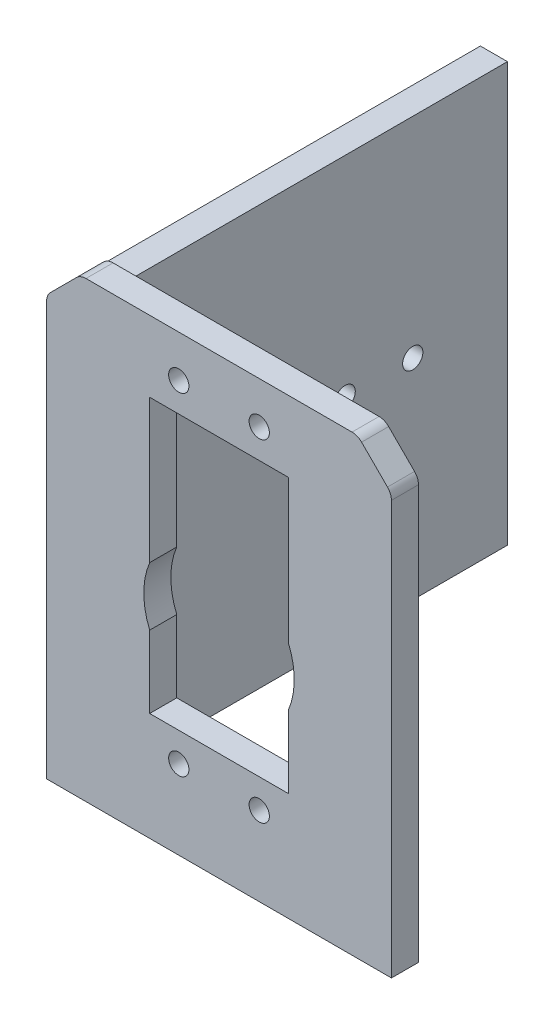
from build123d import *

# Parameters (mm, degrees)
SKETCH1_R           = 1.5
BOSS_EXTRUDE3_DEPTH = 4
SKETCH2_W           = 4
SKETCH2_H           = 61.93693974
BOSS_EXTRUDE4_DEPTH = 60
SKETCH3_R           = 1.5
CUT_EXTRUDE2_DEPTH  = 10


with BuildPart() as part:
    # Sketch1 → Boss-Extrude3 (new body)
    with BuildSketch(Plane.XY):
        with BuildLine():
            Line((0, 61.171572875), (0, 0))
            Line((0, 0), (51, 0))
            Line((51, 0), (51, 61.171572875))
            ThreePointArc((51, 61.171572875), (50.847759065, 61.93693974), (50.414213562, 62.585786438))
            Line((50.414213562, 62.585786438), (46.585786438, 66.414213562))
            ThreePointArc((46.585786438, 66.414213562), (45.93693974, 66.847759065), (45.171572875, 67))
            Line((45.171572875, 67), (5.828427125, 67))
            ThreePointArc((5.828427125, 67), (5.06306026, 66.847759065), (4.414213562, 66.414213562))
            Line((4.414213562, 66.414213562), (0.585786438, 62.585786438))
            ThreePointArc((0.585786438, 62.585786438), (0.152240935, 61.93693974), (0, 61.171572875))
        make_face()
        with Locations((19.55, 11.7)):
            Circle(SKETCH1_R, mode=Mode.SUBTRACT)
        with Locations((31.45, 11.7)):
            Circle(SKETCH1_R, mode=Mode.SUBTRACT)
        with Locations((31.45, 60.8)):
            Circle(SKETCH1_R, mode=Mode.SUBTRACT)
        with Locations((19.55, 60.8)):
            Circle(SKETCH1_R, mode=Mode.SUBTRACT)
        with BuildLine():
            Line((15.25, 56.5), (35.75, 56.5))
            Line((35.75, 56.5), (35.75, 35.324710973))
            ThreePointArc((35.75, 35.324710973), (36.625, 31), (35.75, 26.675289027))
            Line((35.75, 26.675289027), (35.75, 16))
            Line((35.75, 16), (15.25, 16))
            Line((15.25, 16), (15.25, 26.675289027))
            ThreePointArc((15.25, 26.675289027), (14.375, 31), (15.25, 35.324710973))
            Line((15.25, 35.324710973), (15.25, 56.5))
        make_face(mode=Mode.SUBTRACT)
    extrude(amount=BOSS_EXTRUDE3_DEPTH)

    # Sketch2 → Boss-Extrude4 (add)
    with BuildSketch(Plane(origin=(0, 0, 0), x_dir=(-1, 0, 0), z_dir=(0, 0, -1))):
        with Locations((-2.152240935, 30.96846987)):
            Rectangle(SKETCH2_W, SKETCH2_H)
    extrude(amount=BOSS_EXTRUDE4_DEPTH)

    # Sketch3 → Cut-Extrude2 (cut)
    with BuildSketch(Plane.ZY.offset(-0.152240935)):
        with Locations((-46, 30.96846987)):
            Circle(SKETCH3_R)
        with Locations((-36, 30.96846987)):
            Circle(SKETCH3_R)
    extrude(amount=-CUT_EXTRUDE2_DEPTH, mode=Mode.SUBTRACT)


solid = part.part
